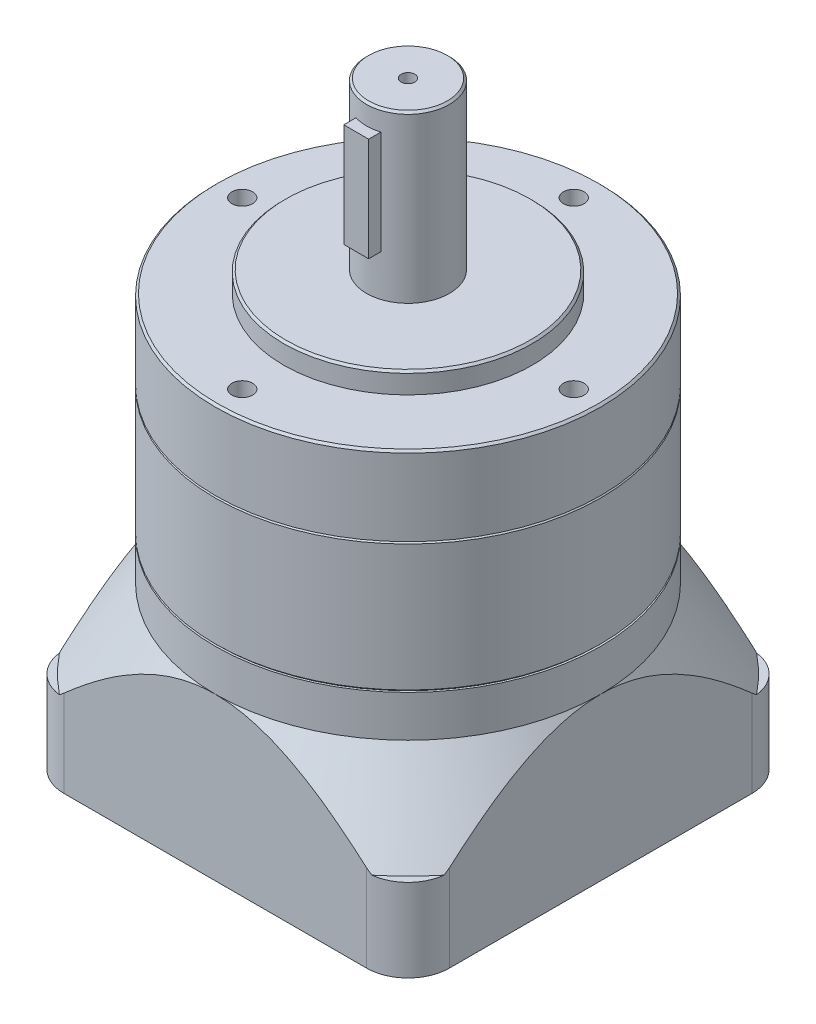
from build123d import *

# Parameters (mm, degrees)
EXTRUDE_1_DEPTH               = 49
CUT_EXTRUDE_START             = -10
SKETCH_2_OUTSIDE_W            = 123.07
SKETCH_2_OUTSIDE_H            = 123.07
SKETCH_2_OUTSIDE_R            = 46.5
CUT_EXTRUDE_3_DEPTH           = 10
CUT_EXTRUDE_3_OTHER_WAY_DEPTH = 19
CUT_EXTRUDE_3_OTHER_WAY_TAPER = 35
SKETCH_3_R                    = 46.5
EXTRUDE_2_DEPTH               = 31.5
SKETCH_4_R                    = 46.5
EXTRUDE_3_DEPTH               = 19
CHAMFER_1_SIZE                = 0.5
SKETCH_6_R                    = 30
EXTRUDE_5_DEPTH               = 5
SKETCH_7_R                    = 10
EXTRUDE_6_DEPTH               = 40
CHAMFER_2_SIZE                = 0.5
PATTERN_CIRCULAR_1_COUNT      = 4
SKETCH_10_W                   = 6
SKETCH_10_H                   = 25
EXTRUDE_7_DEPTH               = 12.5
SKETCH_11_R                   = 35
CUT_EXTRUDE_4_DEPTH           = 6
SKETCH_12_R                   = 10
CUT_EXTRUDE_5_DEPTH           = 40


with BuildPart() as part:
    # 草圖1 → 填料-伸長1 (new body)
    with BuildSketch(Plane(origin=(0, 0, 0), x_dir=(1, 0, 0), z_dir=(0, 1, 0))):
        with BuildLine():
            Line((-36.5, -46.5), (36.5, -46.5))
            ThreePointArc((36.5, -46.5), (43.571067812, -43.571067812), (46.5, -36.5))
            Line((46.5, -36.5), (46.5, 36.5))
            ThreePointArc((46.5, 36.5), (43.571067812, 43.571067812), (36.5, 46.5))
            Line((36.5, 46.5), (-36.5, 46.5))
            ThreePointArc((-36.5, 46.5), (-43.571067812, 43.571067812), (-46.5, 36.5))
            Line((-46.5, 36.5), (-46.5, -36.5))
            ThreePointArc((-46.5, -36.5), (-43.571067812, -43.571067812), (-36.5, -46.5))
        make_face()
    extrude(amount=EXTRUDE_1_DEPTH)

    # 草圖2 outside → 除料-伸長3 (cut)
    with BuildSketch(Plane(origin=(0, 49, 0), x_dir=(1, 0, 0), z_dir=(0, 1, 0)).offset(CUT_EXTRUDE_START)):
        Rectangle(SKETCH_2_OUTSIDE_W, SKETCH_2_OUTSIDE_H)
        with Locations(Location((0, 0, 0), (0, 0, 270))):  # turned: the seam where the file's is
            Circle(SKETCH_2_OUTSIDE_R, mode=Mode.SUBTRACT)
    extrude(amount=CUT_EXTRUDE_3_DEPTH, mode=Mode.SUBTRACT)

    # 草圖2 outside → 除料-伸長3 other way (cut)
    with BuildSketch(Plane(origin=(0, 49, 0), x_dir=(1, 0, 0), z_dir=(0, 1, 0)).offset(CUT_EXTRUDE_START)):
        Rectangle(SKETCH_2_OUTSIDE_W, SKETCH_2_OUTSIDE_H)
        with Locations(Location((0, 0, 0), (0, 0, 270))):  # turned: the seam where the file's is
            Circle(SKETCH_2_OUTSIDE_R, mode=Mode.SUBTRACT)
    extrude(amount=-CUT_EXTRUDE_3_OTHER_WAY_DEPTH, taper=CUT_EXTRUDE_3_OTHER_WAY_TAPER, mode=Mode.SUBTRACT)

    # 草圖11 → 除料-伸長4 (cut)
    with BuildSketch(Plane.XZ):
        with Locations(Location((0, 0, 0), (0, 0, 270))):  # turned: the seam where the file's is
            Circle(SKETCH_11_R)
    extrude(amount=-CUT_EXTRUDE_4_DEPTH, mode=Mode.SUBTRACT)

    # 草圖12 → 除料-伸長5 (cut)
    with BuildSketch(Plane.XZ.offset(-6)):
        with Locations(Location((0, 0, 0), (0, 0, 90))):  # turned: the seam where the file's is
            Circle(SKETCH_12_R)
    extrude(amount=-CUT_EXTRUDE_5_DEPTH, mode=Mode.SUBTRACT)


with BuildPart() as body_2:
    # 草圖3 → 填料-伸長2 (new body)
    with BuildSketch(Plane(origin=(0, 49, 0), x_dir=(1, 0, 0), z_dir=(0, 1, 0))):
        with Locations(Location((0, 0, 0), (0, 0, 270))):  # turned: the seam where the file's is
            Circle(SKETCH_3_R)
    extrude(amount=EXTRUDE_2_DEPTH)

    # 導角1
    chamfer_1_edges = [body_2.edges().sort_by_distance(p)[0] for p in [
        (0, 49, -46.5),
        (0, 80.5, -46.5),
    ]]
    chamfer(chamfer_1_edges, length=CHAMFER_1_SIZE)


with BuildPart() as body_3:
    # 草圖4 → 填料-伸長3 (new body)
    with BuildSketch(Plane(origin=(0, 80.5, 0), x_dir=(1, 0, 0), z_dir=(0, 1, 0))):
        with Locations(Location((0, 0, 0), (0, 0, 270))):  # turned: the seam where the file's is
            Circle(SKETCH_4_R)
    extrude(amount=EXTRUDE_3_DEPTH)

    # 草圖6 → 填料-伸長5 (add)
    with BuildSketch(Plane(origin=(0, 99.5, 0), x_dir=(1, 0, 0), z_dir=(0, 1, 0))):
        with Locations(Location((0, 0, 0), (0, 0, 270))):  # turned: the seam where the file's is
            Circle(SKETCH_6_R)
    extrude(amount=EXTRUDE_5_DEPTH)

    # 草圖7 → 填料-伸長6 (add)
    with BuildSketch(Plane(origin=(0, 104.5, 0), x_dir=(1, 0, 0), z_dir=(0, 1, 0))):
        with Locations(Location((0, 0, 0), (0, 0, 270))):  # turned: the seam where the file's is
            Circle(SKETCH_7_R)
    extrude(amount=EXTRUDE_6_DEPTH)

    # 導角2
    chamfer_2_edges = [body_3.edges().sort_by_distance(p)[0] for p in [
        (0, 144.5, -10),
        (0, 99.5, -46.5),
        (0, 104.5, -30),
    ]]
    chamfer(chamfer_2_edges, length=CHAMFER_2_SIZE)

    # 草圖8 → M6x1.0 螺紋孔1 (revolve, cut)
    with BuildSketch(Plane(origin=(0, 99.5, -40), x_dir=(0, 0, 1), z_dir=(1, 0, 0))):
        Polygon((0, 0), (0, 16.502151548), (2.5, 15), (2.5, 0), align=None)
    m6x1_0_1 = revolve(axis=Axis((0, 105.85, -40), (0, -1, 0)), mode=Mode.SUBTRACT)

    # 環狀複製排列1: M6x1.0 螺紋孔1 ×4 about axis
    pattern_circular_1_axis = Axis((0, 0, 0), (0, 1, 0))
    for i in range(1, PATTERN_CIRCULAR_1_COUNT):
        add(m6x1_0_1.rotate(pattern_circular_1_axis, i * 360 / PATTERN_CIRCULAR_1_COUNT), mode=Mode.SUBTRACT)

    # 草圖10 → 填料-伸長7 (add)
    with BuildSketch(Plane.XY):
        with Locations((0, 127)):
            Rectangle(SKETCH_10_W, SKETCH_10_H)
    extrude(amount=EXTRUDE_7_DEPTH)

    # 草圖13 → M4x0.7 螺紋孔1 (revolve, cut)
    with BuildSketch(Plane(origin=(0, 144.5, 0), x_dir=(0, 0, 1), z_dir=(1, 0, 0))):
        Polygon((0, 0), (0, 11.091420021), (1.65, 10.1), (1.65, 0), align=None)
    revolve(axis=Axis((0, 150.85, 0), (0, -1, 0)), mode=Mode.SUBTRACT)


solid = Compound([part.part, body_2.part, body_3.part])
